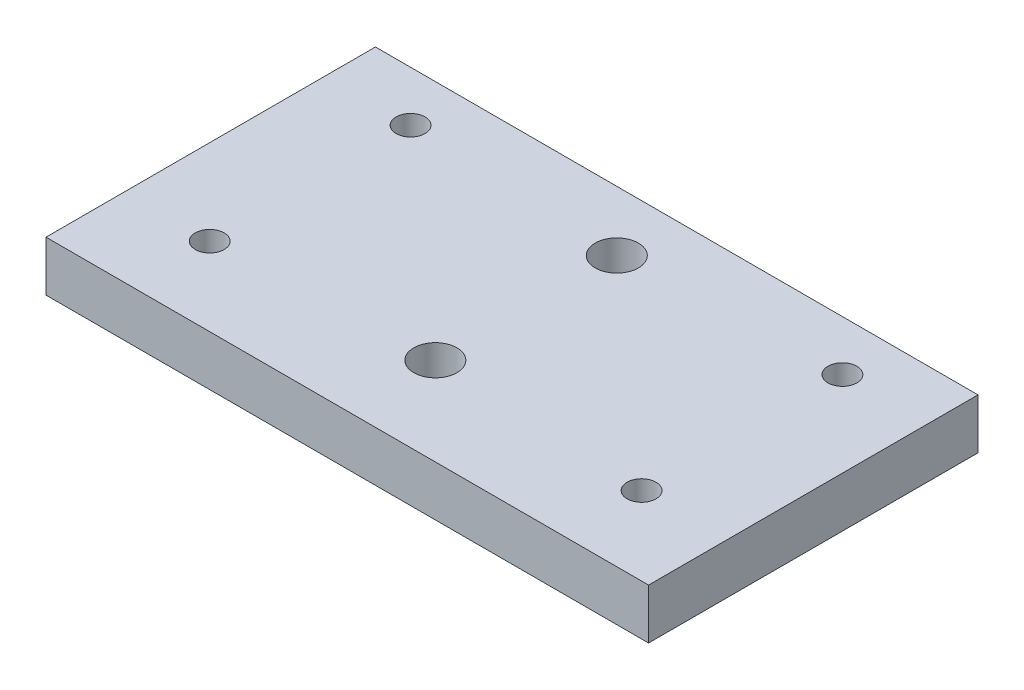
from build123d import *

# Parameters (mm, degrees)
SKETCH1_W               = 76.2
SKETCH1_H               = 152.4
SKETCH1_R               = 2.7305
SKETCH1_R_2             = 1.8288
BOSS_EXTRUDE1_DEPTH     = 6.35
SKETCH2_W               = 76.2
SKETCH2_H               = 110.740191545
CUT_EXTRUDE1_DEPTH      = 1
CUT_EXTRUDE1_DEPTH_BACK = 7.35


with BuildPart() as part:
    # Sketch1 → Boss-Extrude1 (new body)
    with BuildSketch(Plane(origin=(0, 0, 0), x_dir=(1, 0, 0), z_dir=(0, 1, 0))):
        Rectangle(SKETCH1_W, SKETCH1_H)
        with Locations((0, 19.05)):
            Circle(SKETCH1_R, mode=Mode.SUBTRACT)
        with Locations((0, -19.05)):
            Circle(SKETCH1_R, mode=Mode.SUBTRACT)
        with Locations((0, -57.15)):
            Circle(SKETCH1_R, mode=Mode.SUBTRACT)
        with Locations((27.305, 44.45)):
            Circle(SKETCH1_R_2, mode=Mode.SUBTRACT)
        with Locations((27.305, 6.35)):
            Circle(SKETCH1_R_2, mode=Mode.SUBTRACT)
        with Locations((27.305, -31.75)):
            Circle(SKETCH1_R_2, mode=Mode.SUBTRACT)
        with Locations((-27.305, 6.35)):
            Circle(SKETCH1_R_2, mode=Mode.SUBTRACT)
        with Locations((-27.305, -31.75)):
            Circle(SKETCH1_R_2, mode=Mode.SUBTRACT)
        with Locations((-27.305, 44.45)):
            Circle(SKETCH1_R_2, mode=Mode.SUBTRACT)
        with Locations((0, 45.6779905)):
            Circle(SKETCH1_R, mode=Mode.SUBTRACT)
        with Locations((27.305, 69.85)):
            Circle(SKETCH1_R_2, mode=Mode.SUBTRACT)
        with Locations((-27.305, 69.85)):
            Circle(SKETCH1_R_2, mode=Mode.SUBTRACT)
        with Locations((0, 68.6220095)):
            Circle(SKETCH1_R, mode=Mode.SUBTRACT)
    extrude(amount=-BOSS_EXTRUDE1_DEPTH)

    # Sketch2 → Cut-Extrude1 (cut, two sides)
    with BuildSketch(Plane(origin=(0, 0, 0), x_dir=(1, 0, 0), z_dir=(0, 1, 0))) as cut_extrude1_sk:
        with Locations((0, -20.829904228)):
            Rectangle(SKETCH2_W, SKETCH2_H)
    extrude(amount=CUT_EXTRUDE1_DEPTH, mode=Mode.SUBTRACT)
    extrude(cut_extrude1_sk.sketch, amount=-CUT_EXTRUDE1_DEPTH_BACK, mode=Mode.SUBTRACT)


solid = part.part
